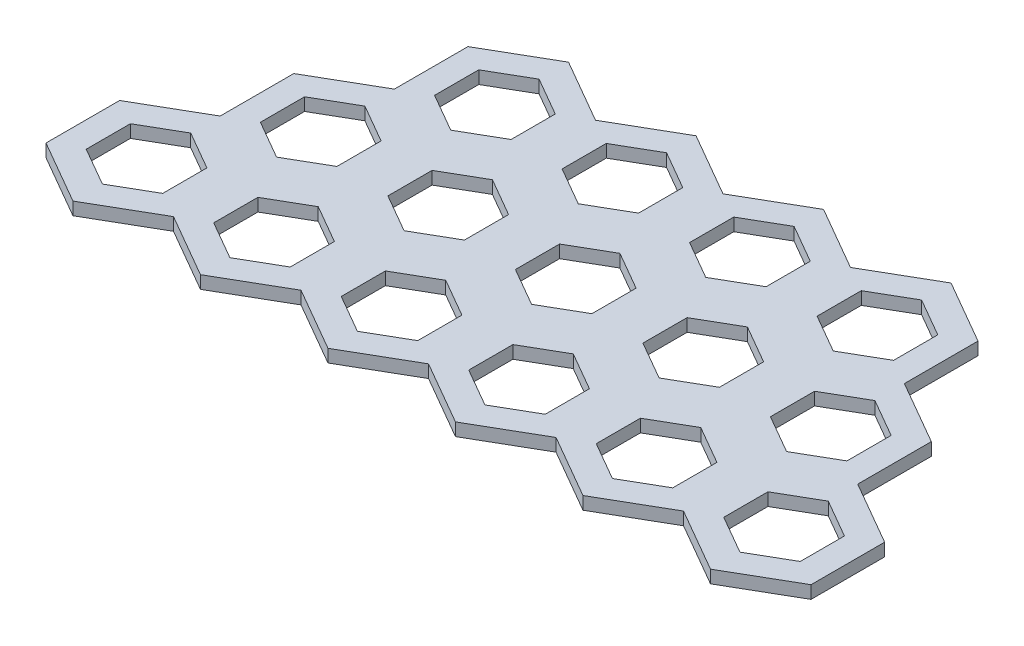
from build123d import *

# Parameters (mm, degrees)
BOSS_EXTRUDE2_DEPTH = 0.5


with BuildPart() as part:
    # Sketch1 → Boss-Extrude2 (new body)
    with BuildSketch(Plane(origin=(0, 0, 0), x_dir=(1, 0, 0), z_dir=(0, 1, 0))):
        Polygon((-2.5, -7.216878365), (0, -5.773502692), (0, -2.886751346), (-2.5, -1.443375673), (-5, -2.886751346), (-5, -5.773502692), align=None)
        Polygon((-1, -3.464101615), (-2.5, -2.598076211), (-4, -3.464101615), (-4, -5.196152423), (-2.5, -6.062177826), (-1, -5.196152423), align=None, mode=Mode.SUBTRACT)
        Polygon((-5, -11.547005384), (-2.5, -10.103629711), (-2.5, -7.216878365), (-5, -5.773502692), (-7.5, -7.216878365), (-7.5, -10.103629711), align=None)
        Polygon((-3.5, -7.794228634), (-5, -6.92820323), (-6.5, -7.794228634), (-6.5, -9.526279442), (-5, -10.392304845), (-3.5, -9.526279442), align=None, mode=Mode.SUBTRACT)
        Polygon((0, -11.547005384), (2.5, -10.103629711), (2.5, -7.216878365), (0, -5.773502692), (-2.5, -7.216878365), (-2.5, -10.103629711), align=None)
        Polygon((1.5, -7.794228634), (0, -6.92820323), (-1.5, -7.794228634), (-1.5, -9.526279442), (0, -10.392304845), (1.5, -9.526279442), align=None, mode=Mode.SUBTRACT)
        Polygon((5, -11.547005384), (7.5, -10.103629711), (7.5, -7.216878365), (5, -5.773502692), (2.5, -7.216878365), (2.5, -10.103629711), align=None)
        Polygon((6.5, -7.794228634), (5, -6.92820323), (3.5, -7.794228634), (3.5, -9.526279442), (5, -10.392304845), (6.5, -9.526279442), align=None, mode=Mode.SUBTRACT)
        Polygon((2.5, -7.216878365), (5, -5.773502692), (5, -2.886751346), (2.5, -1.443375673), (0, -2.886751346), (0, -5.773502692), align=None)
        Polygon((4, -3.464101615), (2.5, -2.598076211), (1, -3.464101615), (1, -5.196152423), (2.5, -6.062177826), (4, -5.196152423), align=None, mode=Mode.SUBTRACT)
        Polygon((2.5, -1.443375673), (2.5, 1.443375673), (0, 2.886751346), (-2.5, 1.443375673), (-2.5, -1.443375673), (0, -2.886751346), align=None)
        Polygon((1.5, 0.866025404), (0, 1.732050808), (-1.5, 0.866025404), (-1.5, -0.866025404), (0, -1.732050808), (1.5, -0.866025404), align=None, mode=Mode.SUBTRACT)
        Polygon((7.5, -1.443375673), (7.5, 1.443375673), (5, 2.886751346), (2.5, 1.443375673), (2.5, -1.443375673), (5, -2.886751346), align=None)
        Polygon((6.5, 0.866025404), (5, 1.732050808), (3.5, 0.866025404), (3.5, -0.866025404), (5, -1.732050808), (6.5, -0.866025404), align=None, mode=Mode.SUBTRACT)
        Polygon((7.5, -7.216878365), (10, -5.773502692), (10, -2.886751346), (7.5, -1.443375673), (5, -2.886751346), (5, -5.773502692), align=None)
        Polygon((9, -3.464101615), (7.5, -2.598076211), (6, -3.464101615), (6, -5.196152423), (7.5, -6.062177826), (9, -5.196152423), align=None, mode=Mode.SUBTRACT)
        Polygon((10, -11.547005384), (12.5, -10.103629711), (12.5, -7.216878365), (10, -5.773502692), (7.5, -7.216878365), (7.5, -10.103629711), align=None)
        Polygon((11.5, -7.794228634), (10, -6.92820323), (8.5, -7.794228634), (8.5, -9.526279442), (10, -10.392304845), (11.5, -9.526279442), align=None, mode=Mode.SUBTRACT)
        Polygon((22.5, -10.103629711), (22.5, -7.216878365), (20, -5.773502692), (17.5, -7.216878365), (17.5, -10.103629711), (20, -11.547005384), align=None)
        Polygon((21.5, -7.794228634), (20, -6.92820323), (18.5, -7.794228634), (18.5, -9.526279442), (20, -10.392304845), (21.5, -9.526279442), align=None, mode=Mode.SUBTRACT)
        Polygon((15, -11.547005384), (17.5, -10.103629711), (17.5, -7.216878365), (15, -5.773502692), (12.5, -7.216878365), (12.5, -10.103629711), align=None)
        Polygon((16.5, -7.794228634), (15, -6.92820323), (13.5, -7.794228634), (13.5, -9.526279442), (15, -10.392304845), (16.5, -9.526279442), align=None, mode=Mode.SUBTRACT)
        Polygon((20, -5.773502692), (20, -2.886751346), (17.5, -1.443375673), (15, -2.886751346), (15, -5.773502692), (17.5, -7.216878365), align=None)
        Polygon((19, -3.464101615), (17.5, -2.598076211), (16, -3.464101615), (16, -5.196152423), (17.5, -6.062177826), (19, -5.196152423), align=None, mode=Mode.SUBTRACT)
        Polygon((12.5, -7.216878365), (15, -5.773502692), (15, -2.886751346), (12.5, -1.443375673), (10, -2.886751346), (10, -5.773502692), align=None)
        Polygon((14, -3.464101615), (12.5, -2.598076211), (11, -3.464101615), (11, -5.196152423), (12.5, -6.062177826), (14, -5.196152423), align=None, mode=Mode.SUBTRACT)
        Polygon((17.5, -1.443375673), (17.5, 1.443375673), (15, 2.886751346), (12.5, 1.443375673), (12.5, -1.443375673), (15, -2.886751346), align=None)
        Polygon((16.5, 0.866025404), (15, 1.732050808), (13.5, 0.866025404), (13.5, -0.866025404), (15, -1.732050808), (16.5, -0.866025404), align=None, mode=Mode.SUBTRACT)
        Polygon((12.5, -1.443375673), (12.5, 1.443375673), (10, 2.886751346), (7.5, 1.443375673), (7.5, -1.443375673), (10, -2.886751346), align=None)
        Polygon((11.5, 0.866025404), (10, 1.732050808), (8.5, 0.866025404), (8.5, -0.866025404), (10, -1.732050808), (11.5, -0.866025404), align=None, mode=Mode.SUBTRACT)
    extrude(amount=BOSS_EXTRUDE2_DEPTH)


solid = part.part
